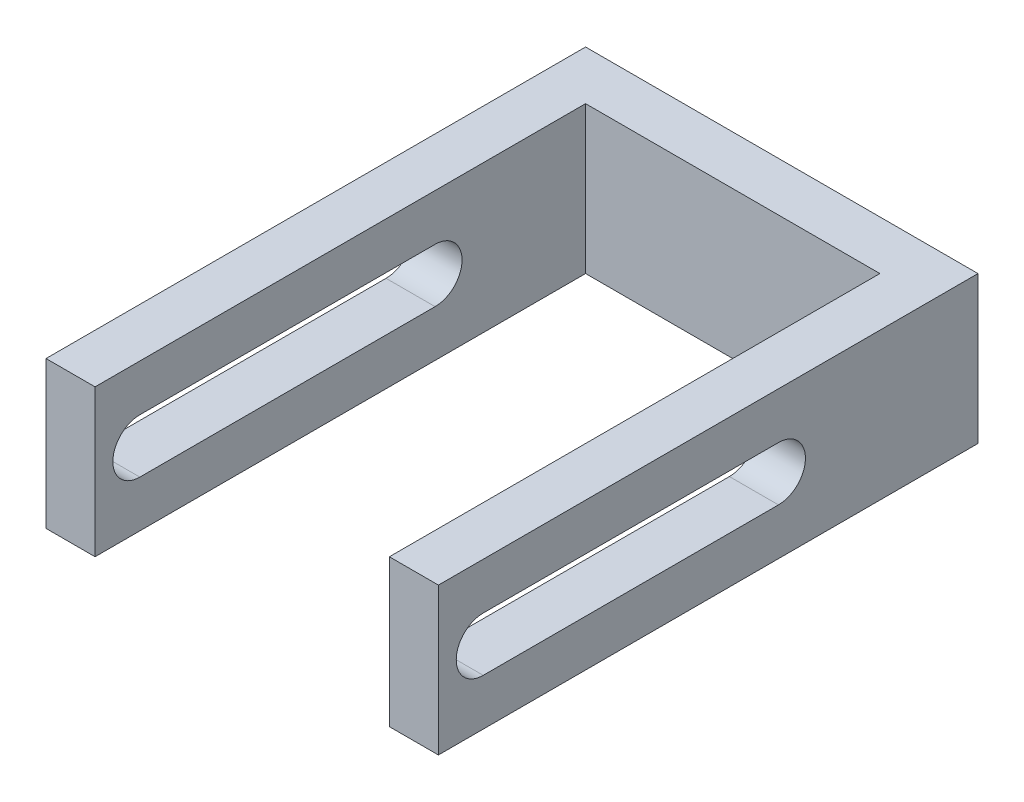
from build123d import *

# Parameters (mm, degrees)
BOSS_EXTRUDE1_DEPTH = 15
CUT_EXTRUDE1_DEPTH  = 41


with BuildPart() as part:
    # Sketch1 → Boss-Extrude1 (new body)
    with BuildSketch(Plane(origin=(0, 0, 0), x_dir=(1, 0, 0), z_dir=(0, 1, 0))):
        Polygon((0, 0), (-5, 0), (-5, 55), (23.965517241, 55), (35, 55), (35, 0), (30, 0), (30, 50), (0, 50), align=None)
    extrude(amount=BOSS_EXTRUDE1_DEPTH)

    # Sketch2 → Cut-Extrude1 (cut, through all)
    with BuildSketch(Plane(origin=(35, 0, 0), x_dir=(0, 0, -1), z_dir=(1, 0, 0))):
        with BuildLine():
            Line((4.564965869, 10.25), (34.659838249, 10.25))
            ThreePointArc((34.659838249, 10.25), (37.409838249, 7.5), (34.659838249, 4.75))
            Line((34.659838249, 4.75), (4.564965869, 4.75))
            ThreePointArc((4.564965869, 4.75), (1.814965869, 7.5), (4.564965869, 10.25))
        make_face()
    extrude(amount=-CUT_EXTRUDE1_DEPTH, mode=Mode.SUBTRACT)


solid = part.part
